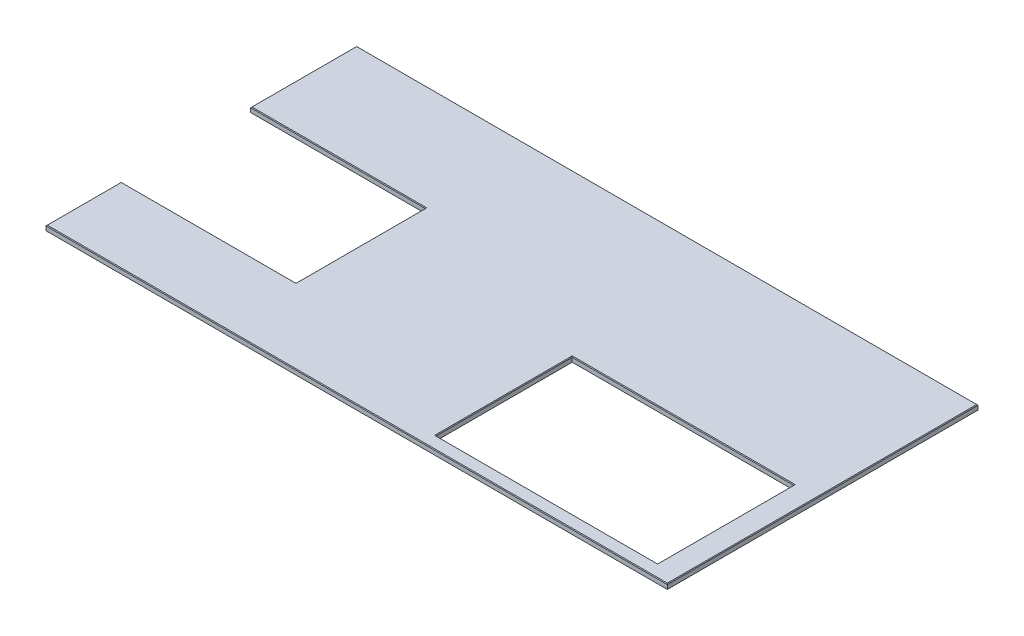
from build123d import *

# Parameters (mm, degrees)
SKETCH1_W           = 869.95
SKETCH1_H           = 534.924
BOSS_EXTRUDE1_DEPTH = 19.05
CHAMFER1_SIZE       = 2.54


with BuildPart() as part:
    # Sketch1 → Boss-Extrude1 (new body)
    with BuildSketch(Plane(origin=(0, 0, 0), x_dir=(1, 0, 0), z_dir=(0, 1, 0))):
        Polygon((2438.4, 0), (2438.4, 1219.2), (0, 1219.2), (0, 803.275), (685.8, 803.275), (685.8, 295.275), (0, 295.275), (0, 0), align=None)
        with Locations((1914.4615, 318.262)):
            Rectangle(SKETCH1_W, SKETCH1_H, mode=Mode.SUBTRACT)
    extrude(amount=-BOSS_EXTRUDE1_DEPTH)

    # Chamfer1
    chamfer1_edges = [part.edges().sort_by_distance(p)[0] for p in [
        (0, 0, -1011.2375),
        (1219.2, 0, -1219.2),
        (2438.4, 0, -609.6),
        (1219.2, 0, 0),
        (1914.4615, 0, -585.724),
        (1479.4865, 0, -318.262),
        (1914.4615, 0, -50.8),
        (2349.4365, 0, -318.262),
        (0, 0, -147.6375),
        (342.9, 0, -295.275),
        (685.8, 0, -549.275),
        (342.9, 0, -803.275),
    ]]
    chamfer(chamfer1_edges, length=CHAMFER1_SIZE)


solid = part.part
